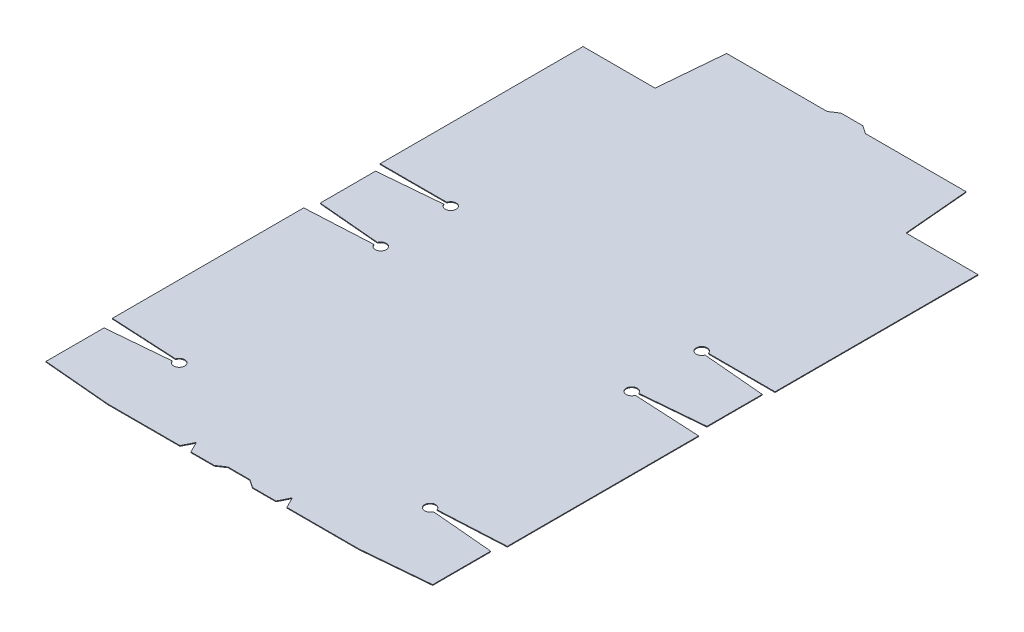
from build123d import *

# Parameters (mm, degrees)
EXTRUDE1_DEPTH = 0.79375
EXTRUDE2_REACH = 2.794
SKETCH2_R      = 6.35
EXTRUDE3_REACH = 2.794
EXTRUDE4_REACH = 2.794


with BuildPart() as part:
    # Sketch1 → Extrude1 (new body)
    with BuildSketch(Plane(origin=(0, 0, 0), x_dir=(1, 0, 0), z_dir=(0, 1, 0))):
        with BuildLine():
            Line((145.25625, 434.18125), (138.034060826, 516.73125))
            Line((138.034060826, 516.73125), (-138.034060826, 516.73125))
            Line((-138.034060826, 516.73125), (-145.25625, 434.18125))
            Line((-145.25625, 434.18125), (-228.6, 434.18125))
            Line((-228.6, 434.18125), (-228.6, 199.23125))
            Line((-228.6, 199.23125), (-145.25625, 199.23125))
            ThreePointArc((-145.25625, 199.23125), (-143.670260948, 197.712995777), (-145.117890258, 196.062290917))
            Line((-145.117890258, 196.062290917), (-223.8375, 189.175217467))
            Line((-223.8375, 189.175217467), (-223.8375, 125.149782533))
            Line((-223.8375, 125.149782533), (-145.117890258, 118.262709083))
            ThreePointArc((-145.117890258, 118.262709083), (-143.668991784, 116.653544305), (-145.173166669, 115.095925614))
            Line((-145.173166669, 115.095925614), (-228.6, 110.723710546))
            Line((-228.6, 110.723710546), (-228.6, -110.723710546))
            Line((-228.6, -110.723710546), (-145.173166669, -115.095925614))
            ThreePointArc((-145.173166669, -115.095925614), (-143.668991784, -116.653544305), (-145.117890258, -118.262709083))
            Line((-145.117890258, -118.262709083), (-223.8375, -125.149782533))
            Line((-223.8375, -125.149782533), (-223.8375, -192.356281459))
            Line((-223.8375, -192.356281459), (-145.25625, -199.23125))
            Line((-145.25625, -199.23125), (145.25625, -199.23125))
            Line((145.25625, -199.23125), (223.8375, -192.356281459))
            Line((223.8375, -192.356281459), (223.8375, -125.149782533))
            Line((223.8375, -125.149782533), (145.117890258, -118.262709083))
            ThreePointArc((145.117890258, -118.262709083), (143.668991784, -116.653544305), (145.173166669, -115.095925614))
            Line((145.173166669, -115.095925614), (228.6, -110.723710546))
            Line((228.6, -110.723710546), (228.6, 110.723710546))
            Line((228.6, 110.723710546), (145.173166669, 115.095925614))
            ThreePointArc((145.173166669, 115.095925614), (143.668991784, 116.653544305), (145.117890258, 118.262709083))
            Line((145.117890258, 118.262709083), (223.8375, 125.149782533))
            Line((223.8375, 125.149782533), (223.8375, 189.175217467))
            Line((223.8375, 189.175217467), (145.117890258, 196.062290917))
            ThreePointArc((145.117890258, 196.062290917), (143.670260948, 197.712995777), (145.25625, 199.23125))
            Line((145.25625, 199.23125), (228.6, 199.23125))
            Line((228.6, 199.23125), (228.6, 434.18125))
            Line((228.6, 434.18125), (145.25625, 434.18125))
        make_face()
    extrude(amount=EXTRUDE1_DEPTH)

    # Sketch2 → Extrude2 (cut, up to next)
    with BuildSketch(Plane(origin=(0, 0.79375, 0), x_dir=(1, 0, 0), z_dir=(0, 1, 0)), mode=Mode.PRIVATE) as extrude2_sk1:
        with Locations((-145.25625, 116.68125)):
            Circle(SKETCH2_R)
    extrude2_tool1 = extrude(extrude2_sk1.sketch, amount=-EXTRUDE2_REACH, mode=Mode.PRIVATE) & part.part
    add(extrude2_tool1.solids().sort_by_distance((-145.25625, 0.79375, -116.68125))[0], mode=Mode.SUBTRACT)
    # Sketch2 → Extrude2 (cut, up to next)
    with BuildSketch(Plane(origin=(0, 0.79375, 0), x_dir=(1, 0, 0), z_dir=(0, 1, 0)), mode=Mode.PRIVATE) as extrude2_sk2:
        with Locations((-145.25625, -116.68125)):
            Circle(SKETCH2_R)
    extrude2_tool2 = extrude(extrude2_sk2.sketch, amount=-EXTRUDE2_REACH, mode=Mode.PRIVATE) & part.part
    add(extrude2_tool2.solids().sort_by_distance((-145.25625, 0.79375, 116.68125))[0], mode=Mode.SUBTRACT)
    # Sketch2 → Extrude2 (cut, up to next)
    with BuildSketch(Plane(origin=(0, 0.79375, 0), x_dir=(1, 0, 0), z_dir=(0, 1, 0)), mode=Mode.PRIVATE) as extrude2_sk3:
        with Locations((145.25625, -116.68125)):
            Circle(SKETCH2_R)
    extrude2_tool3 = extrude(extrude2_sk3.sketch, amount=-EXTRUDE2_REACH, mode=Mode.PRIVATE) & part.part
    add(extrude2_tool3.solids().sort_by_distance((145.25625, 0.79375, 116.68125))[0], mode=Mode.SUBTRACT)
    # Sketch2 → Extrude2 (cut, up to next)
    with BuildSketch(Plane(origin=(0, 0.79375, 0), x_dir=(1, 0, 0), z_dir=(0, 1, 0)), mode=Mode.PRIVATE) as extrude2_sk4:
        with Locations((145.25625, 116.68125)):
            Circle(SKETCH2_R)
    extrude2_tool4 = extrude(extrude2_sk4.sketch, amount=-EXTRUDE2_REACH, mode=Mode.PRIVATE) & part.part
    add(extrude2_tool4.solids().sort_by_distance((145.25625, 0.79375, -116.68125))[0], mode=Mode.SUBTRACT)
    # Sketch2 → Extrude2 (cut, up to next)
    with BuildSketch(Plane(origin=(0, 0.79375, 0), x_dir=(1, 0, 0), z_dir=(0, 1, 0)), mode=Mode.PRIVATE) as extrude2_sk5:
        with Locations((-145.25625, 197.64375)):
            Circle(SKETCH2_R)
    extrude2_tool5 = extrude(extrude2_sk5.sketch, amount=-EXTRUDE2_REACH, mode=Mode.PRIVATE) & part.part
    add(extrude2_tool5.solids().sort_by_distance((-145.25625, 0.79375, -197.64375))[0], mode=Mode.SUBTRACT)
    # Sketch2 → Extrude2 (cut, up to next)
    with BuildSketch(Plane(origin=(0, 0.79375, 0), x_dir=(1, 0, 0), z_dir=(0, 1, 0)), mode=Mode.PRIVATE) as extrude2_sk6:
        with Locations((145.25625, 197.64375)):
            Circle(SKETCH2_R)
    extrude2_tool6 = extrude(extrude2_sk6.sketch, amount=-EXTRUDE2_REACH, mode=Mode.PRIVATE) & part.part
    add(extrude2_tool6.solids().sort_by_distance((145.25625, 0.79375, -197.64375))[0], mode=Mode.SUBTRACT)

    # Sketch12 → Extrude3 (cut, up to next)
    with BuildSketch(Plane(origin=(0, 0.79375, 0), x_dir=(1, 0, 0), z_dir=(0, 1, 0)), mode=Mode.PRIVATE) as extrude3_sk1:
        Polygon((-138.589613839, 510.38125), (-22.225, 510.38125), (-12.7, 516.73125), (-138.034060826, 516.73125), align=None)
    extrude3_tool1 = extrude(extrude3_sk1.sketch, amount=-EXTRUDE3_REACH, mode=Mode.PRIVATE) & part.part
    add(extrude3_tool1.solids().sort_by_distance((-77.855995, 0.79375, -513.595525))[0], mode=Mode.SUBTRACT)
    # Sketch12 → Extrude3 (cut, up to next)
    with BuildSketch(Plane(origin=(0, 0.79375, 0), x_dir=(1, 0, 0), z_dir=(0, 1, 0)), mode=Mode.PRIVATE) as extrude3_sk2:
        Polygon((12.7, 516.73125), (22.225, 510.38125), (138.589613839, 510.38125), (138.034060826, 516.73125), align=None)
    extrude3_tool2 = extrude(extrude3_sk2.sketch, amount=-EXTRUDE3_REACH, mode=Mode.PRIVATE) & part.part
    add(extrude3_tool2.solids().sort_by_distance((77.855995, 0.79375, -513.595525))[0], mode=Mode.SUBTRACT)

    # Sketch13 → Extrude4 (cut, up to next)
    with BuildSketch(Plane(origin=(0, 0.79375, 0), x_dir=(1, 0, 0), z_dir=(0, 1, 0)), mode=Mode.PRIVATE) as extrude4_sk1:
        Polygon((-61.9125, -199.23125), (-55.5625, -186.53125), (-49.2125, -199.23125), align=None)
    extrude4_tool1 = extrude(extrude4_sk1.sketch, amount=-EXTRUDE4_REACH, mode=Mode.PRIVATE) & part.part
    add(extrude4_tool1.solids().sort_by_distance((-55.5625, 0.79375, 194.997917))[0], mode=Mode.SUBTRACT)
    # Sketch13 → Extrude4 (cut, up to next)
    with BuildSketch(Plane(origin=(0, 0.79375, 0), x_dir=(1, 0, 0), z_dir=(0, 1, 0)), mode=Mode.PRIVATE) as extrude4_sk2:
        Polygon((49.2125, -199.23125), (55.5625, -186.53125), (61.9125, -199.23125), align=None)
    extrude4_tool2 = extrude(extrude4_sk2.sketch, amount=-EXTRUDE4_REACH, mode=Mode.PRIVATE) & part.part
    add(extrude4_tool2.solids().sort_by_distance((55.5625, 0.79375, 194.997917))[0], mode=Mode.SUBTRACT)
    # Sketch13 → Extrude4 (cut, up to next)
    with BuildSketch(Plane(origin=(0, 0.79375, 0), x_dir=(1, 0, 0), z_dir=(0, 1, 0)), mode=Mode.PRIVATE) as extrude4_sk3:
        Polygon((-22.225, -199.23125), (-12.7, -192.88125), (12.7, -192.88125), (22.225, -199.23125), align=None)
    extrude4_tool3 = extrude(extrude4_sk3.sketch, amount=-EXTRUDE4_REACH, mode=Mode.PRIVATE) & part.part
    add(extrude4_tool3.solids().sort_by_distance((0, 0.79375, 196.344886))[0], mode=Mode.SUBTRACT)


solid = part.part
